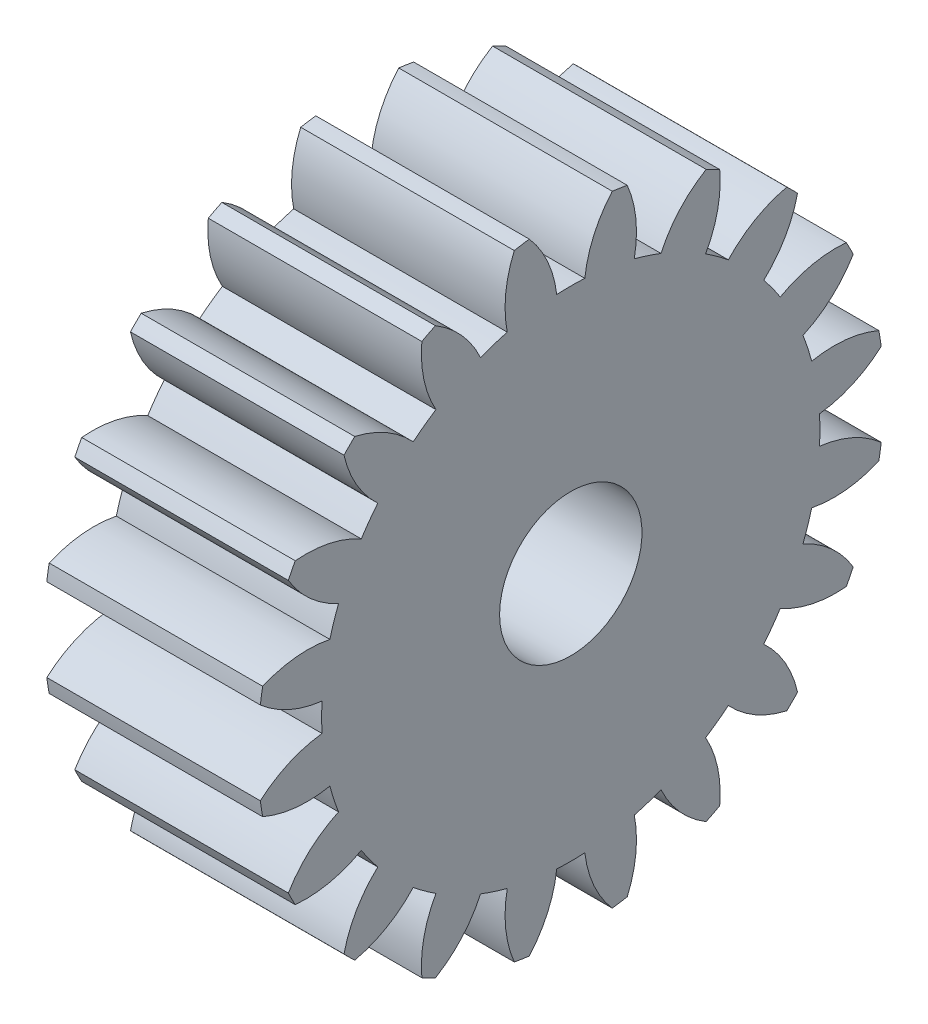
from build123d import *

# Parameters (mm, degrees)
BASPROSKE_W     = 15
BASPROSKE_H     = 22
TOOTHCUT_DEPTH  = 35.539832078
TEETHCUTS_COUNT = 20
TEETHCUTS_ANGLE = 342
BORSKE_R        = 5
BORE_DEPTH      = 50.0000508


with BuildPart() as part:
    # BasProSke → Base-Revolve (revolve)
    with BuildSketch(Plane(origin=(0, 0, 0), x_dir=(1, 0, 0), z_dir=(0, 1, 0)), mode=Mode.PRIVATE) as base_revolve_sk:
        with Locations((7.5, 11)):
            Rectangle(BASPROSKE_W, BASPROSKE_H)
    revolve(base_revolve_sk.sketch.rotate(Axis((-10, 0, 0), (1, 0, 0)), 180), axis=Axis((-10, 0, 0), (1, 0, 0)))

    # TooCutSke → ToothCut (cut, through all)
    with BuildSketch(Plane(origin=(0, 0, 0), x_dir=(0, 0, -1), z_dir=(1, 0, 0))):
        with BuildLine():
            ThreePointArc((0.986171591, 17.471189616), (0, 17.499), (-0.986171591, 17.471189616))
            ThreePointArc((-0.986171591, 17.471189616), (-1.626916196, 19.798789858), (-2.932850173, 21.829260982))
            ThreePointArc((-2.932850173, 21.829260982), (0, 22.0254), (2.932850173, 21.829260982))
            ThreePointArc((2.932850173, 21.829260982), (1.626916196, 19.798789858), (0.986171591, 17.471189616))
        make_face()
    toothcut = extrude(amount=TOOTHCUT_DEPTH, mode=Mode.SUBTRACT)

    # TeethCuts: ToothCut ×20 about axis
    teethcuts_axis = Axis((-10, 0, 0), (1, 0, 0))
    for i in range(1, TEETHCUTS_COUNT):
        add(toothcut.rotate(teethcuts_axis, i * TEETHCUTS_ANGLE / (TEETHCUTS_COUNT - 1)), mode=Mode.SUBTRACT)

    # BorSke → Bore (cut, symmetric)
    with BuildSketch(Plane(origin=(0, 0, 0), x_dir=(0, 0, -1), z_dir=(1, 0, 0))):
        with Locations(Location((0, 0, 0), (0, 0, 180))):
            Circle(BORSKE_R)
    extrude(amount=BORE_DEPTH, both=True, mode=Mode.SUBTRACT)


solid = part.part
